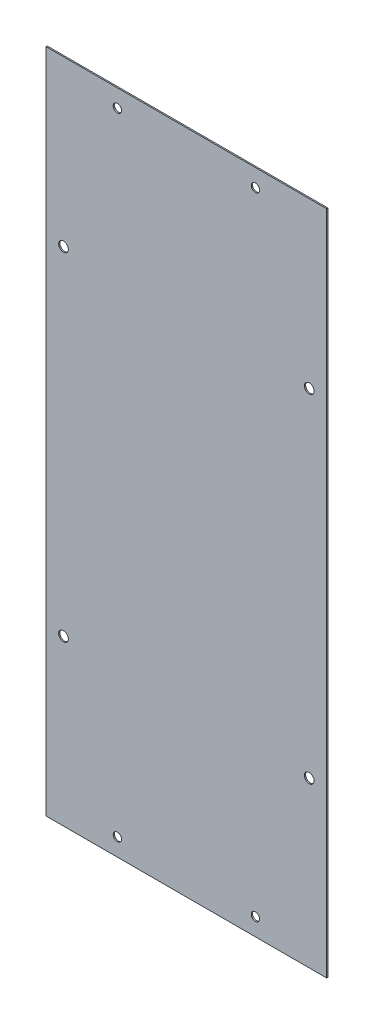
from build123d import *

# Parameters (mm, degrees)
SKETCH_1_W          = 203.2
SKETCH_1_H          = 482.6
EXTRUDE_1_DEPTH     = 0.9
SKETCH_2_R          = 3.5
SKETCH_2_R_2        = 3
CUT_EXTRUDE_1_DEPTH = 10


with BuildPart() as part:
    # 草图1 → 凸台-拉伸1 (new body)
    with BuildSketch(Plane.XY):
        Rectangle(SKETCH_1_W, SKETCH_1_H)
    extrude(amount=EXTRUDE_1_DEPTH)

    # 草图2 → 切除-拉伸1 (cut)
    with BuildSketch(Plane.XY.offset(0.9)):
        with Locations((-89, 122.2)):
            Circle(SKETCH_2_R)
        with Locations((89, 122.2)):
            Circle(SKETCH_2_R)
        with Locations((89, -122.2)):
            Circle(SKETCH_2_R)
        with Locations((-89, -122.2)):
            Circle(SKETCH_2_R)
        with Locations((50, 228.6)):
            Circle(SKETCH_2_R_2)
        with Locations((50, -228.6)):
            Circle(SKETCH_2_R_2)
        with Locations((-50, 228.6)):
            Circle(SKETCH_2_R_2)
        with Locations((-50, -228.6)):
            Circle(SKETCH_2_R_2)
    extrude(amount=-CUT_EXTRUDE_1_DEPTH, mode=Mode.SUBTRACT)


solid = part.part
